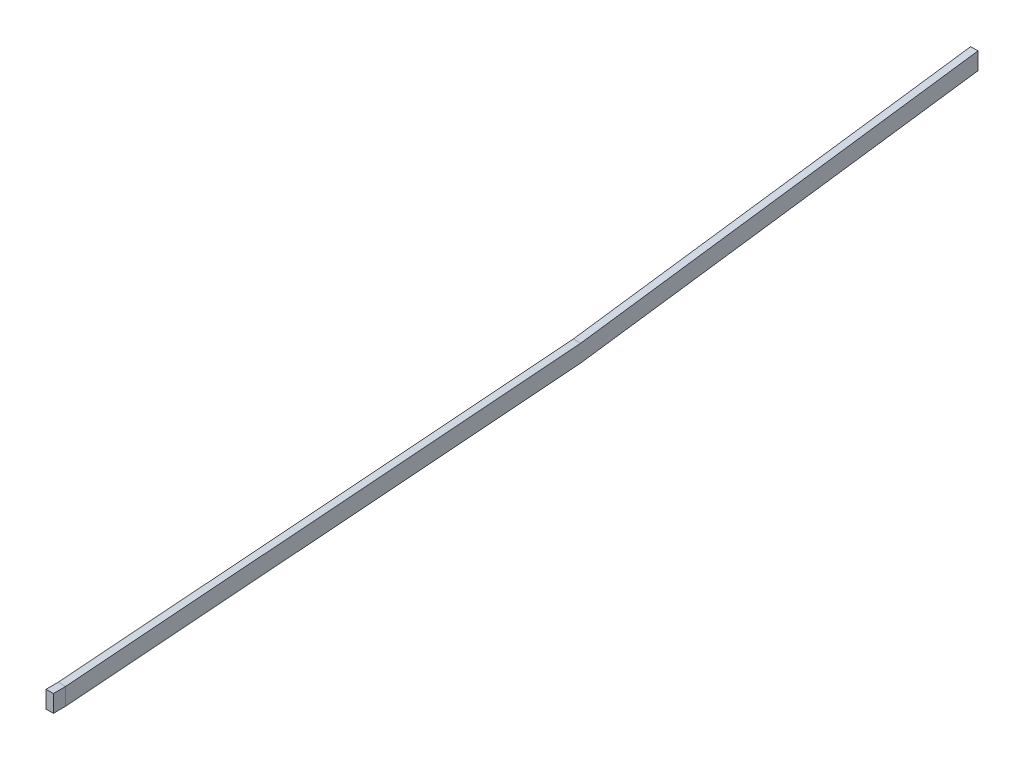
from build123d import *

# Parameters (mm, degrees)
BOSS_EXTRUDE1_DEPTH = 3
SKETCH2_W           = 5
SKETCH2_H           = 7
BOSS_EXTRUDE2_DEPTH = 3


with BuildPart() as part:
    # Sketch1 → Boss-Extrude1 (new body)
    with BuildSketch(Plane(origin=(0, 0, 0), x_dir=(0, 0, -1), z_dir=(1, 0, 0))):
        Polygon((0, 0), (0, 7), (210, 23.195488775), (372, 45.41553397), (372, 38.41553397), (210, 16.195488775), align=None)
    extrude(amount=BOSS_EXTRUDE1_DEPTH)


with BuildPart() as body_2:
    # Sketch2 → Boss-Extrude2 (new body)
    with BuildSketch(Plane(origin=(3, 0, 0), x_dir=(0, 0, -1), z_dir=(1, 0, 0))):
        with Locations((-2.5, 3.5)):
            Rectangle(SKETCH2_W, SKETCH2_H)
    extrude(amount=-BOSS_EXTRUDE2_DEPTH)


solid = Compound([part.part, body_2.part])
